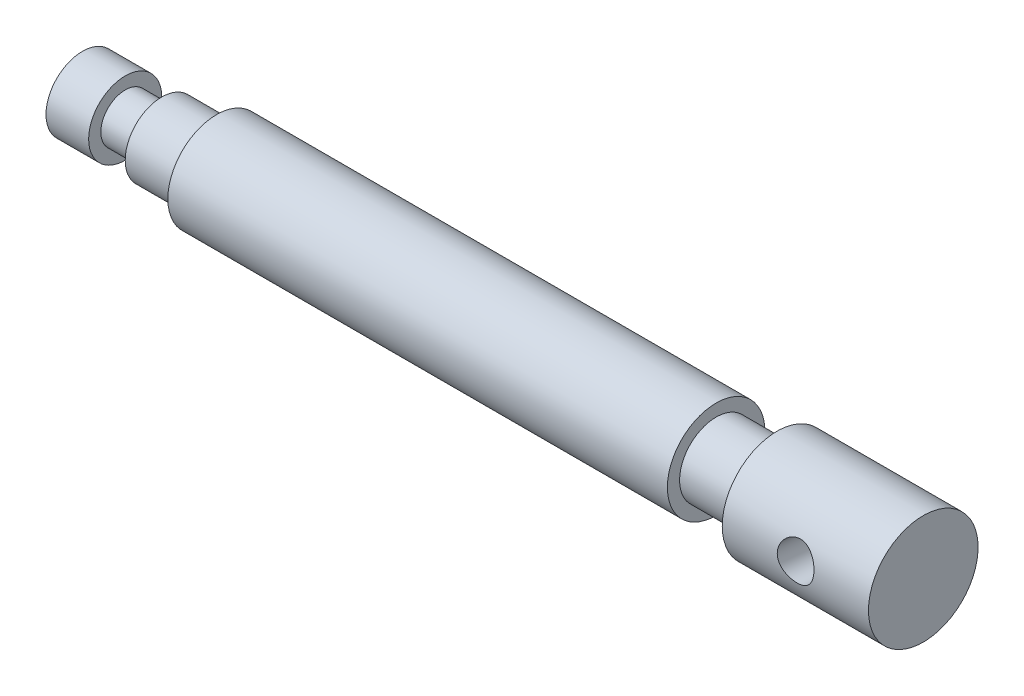
from build123d import *

# Parameters (mm, degrees)
F_6_0MM_DOWEL_HOLE1_D     = 6
F_6_0MM_DOWEL_HOLE1_DEPTH = 76
F_6_0MM_DOWEL_HOLE1_TIP   = 1.802581857


with BuildPart() as part:
    # Sketch1 → Revolve1 (revolve)
    with BuildSketch(Plane.XY):
        Polygon((0, 0), (0, 6), (7, 6), (7, 4), (13, 4), (13, 6), (22, 6), (22, 8), (104, 8), (104, 6), (114, 6), (114, 9), (138, 9), (138, 0), align=None)
    revolve(axis=Axis((-8.88370643, 0, 0), (1, 0, 0)))

    # Ø6.0mm Dowel Hole1
    with Locations(Plane(origin=(126, 0.82123208, 8.962453786), x_dir=(0, 0.995828198, -0.091248009), z_dir=(0, 0.091248009, 0.995828198))):
        with Locations((0, 0)):
            Hole(F_6_0MM_DOWEL_HOLE1_D / 2, depth=F_6_0MM_DOWEL_HOLE1_DEPTH)
            with Locations((0, 0, -(F_6_0MM_DOWEL_HOLE1_DEPTH + F_6_0MM_DOWEL_HOLE1_TIP / 2))):  # 118° drill point
                Cone(0, F_6_0MM_DOWEL_HOLE1_D / 2, F_6_0MM_DOWEL_HOLE1_TIP, mode=Mode.SUBTRACT)


solid = part.part
